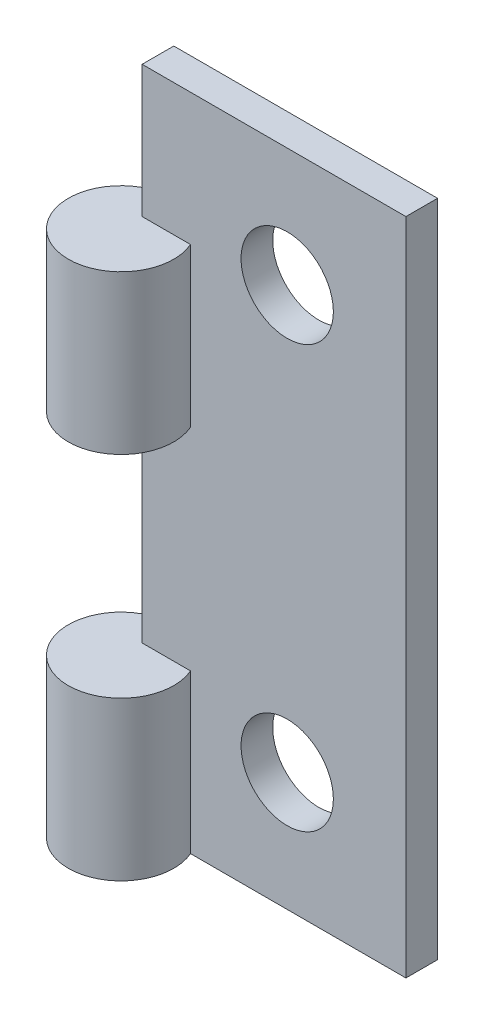
from build123d import *

# Parameters (mm, degrees)
SKETCH_1_W             = 10
SKETCH_1_H             = 25
SKETCH_1_R             = 1.75
EXTRUDE_1_DEPTH        = 1.2
SKETCH_3_R             = 2
EXTRUDE_3_DEPTH        = 6
PATTERN_LINEAR_2_COUNT = 2
PATTERN_LINEAR_2_PITCH = 14


with BuildPart() as part:
    # 草图1 → 凸台-拉伸1 (new body)
    with BuildSketch(Plane.XY):
        Rectangle(SKETCH_1_W, SKETCH_1_H)
        with Locations((0.5, 8)):
            Circle(SKETCH_1_R, mode=Mode.SUBTRACT)
        with Locations((0.5, -8)):
            Circle(SKETCH_1_R, mode=Mode.SUBTRACT)
    extrude(amount=EXTRUDE_1_DEPTH)

    # 草图3 → 凸台-拉伸3 (add)
    with BuildSketch(Plane.XZ.offset(12.5)):
        with Locations((-5, 2)):
            Circle(SKETCH_3_R)
    extrude_3 = extrude(amount=-EXTRUDE_3_DEPTH)

    # 阵列(线性)2: 凸台-拉伸3 ×2
    with Locations(*[(0, i * PATTERN_LINEAR_2_PITCH, 0) for i in range(1, PATTERN_LINEAR_2_COUNT)]):
        add(extrude_3)


solid = part.part
